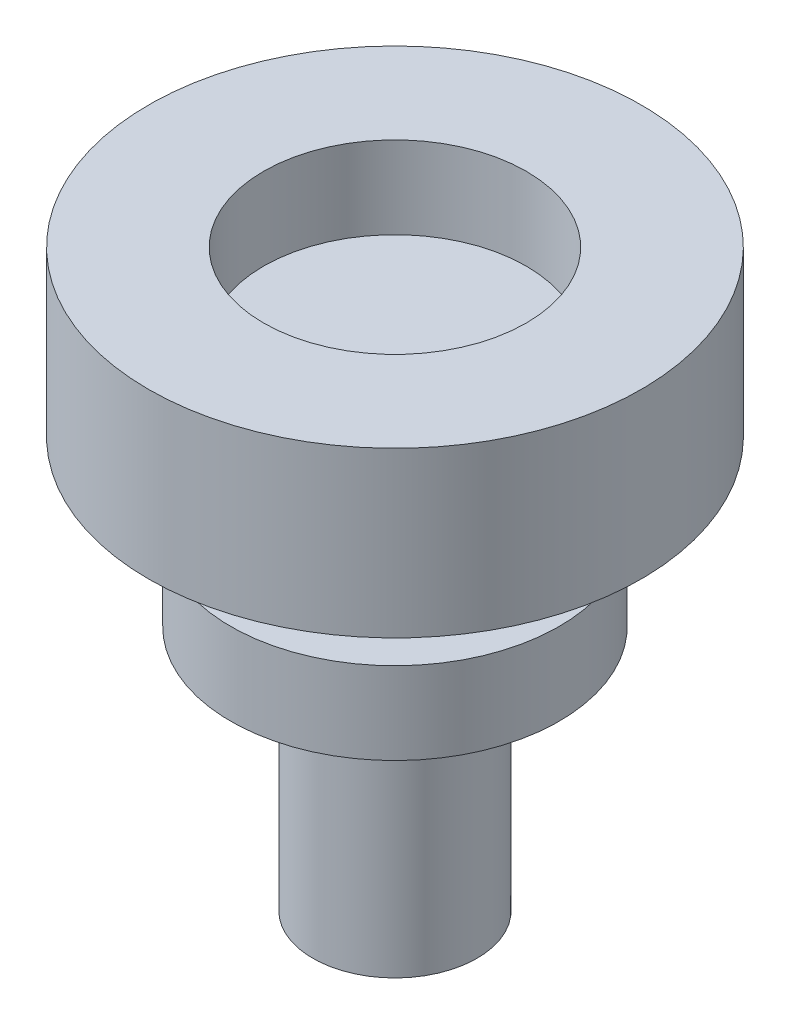
from build123d import *

# Parameters (mm, degrees)
SKETCH1_R           = 3
SKETCH1_R_2         = 1.6
BOSS_EXTRUDE1_DEPTH = 2
SKETCH1_3_R         = 1.6
BOSS_EXTRUDE2_DEPTH = 1
SKETCH5_R           = 1.5
BOSS_EXTRUDE3_DEPTH = 1
SKETCH6_R           = 2
BOSS_EXTRUDE4_DEPTH = 1
SKETCH8_R           = 1
BOSS_EXTRUDE5_DEPTH = 3


with BuildPart() as part:
    # Sketch1 → Boss-Extrude1 (new body)
    with BuildSketch(Plane(origin=(0, 0, 0), x_dir=(1, 0, 0), z_dir=(0, 1, 0))):
        with Locations((-0.522013312, 0.511138034)):
            Circle(SKETCH1_R)
        with Locations((-0.522013312, 0.511138034)):
            Circle(SKETCH1_R_2, mode=Mode.SUBTRACT)
    extrude(amount=BOSS_EXTRUDE1_DEPTH)

    # Sketch1_3 → Boss-Extrude2 (add)
    with BuildSketch(Plane(origin=(0, 0, 0), x_dir=(1, 0, 0), z_dir=(0, 1, 0))):
        with Locations((-0.522013312, 0.511138034)):
            Circle(SKETCH1_3_R)
    extrude(amount=BOSS_EXTRUDE2_DEPTH)

    # Sketch5 → Boss-Extrude3 (add)
    with BuildSketch(Plane.XZ):
        with Locations((-0.522013312, -0.511138034)):
            Circle(SKETCH5_R)
    extrude(amount=BOSS_EXTRUDE3_DEPTH)

    # Sketch6 → Boss-Extrude4 (add)
    with BuildSketch(Plane.XZ.offset(1)):
        with Locations((-0.522013312, -0.511138034)):
            Circle(SKETCH6_R)
    extrude(amount=BOSS_EXTRUDE4_DEPTH)

    # Sketch8 → Boss-Extrude5 (add)
    with BuildSketch(Plane(origin=(0, -2, 0), x_dir=(-1, 0, 0), z_dir=(0, -1, 0))):
        with Locations((0.522013312, 0.511138034)):
            Circle(SKETCH8_R)
    extrude(amount=BOSS_EXTRUDE5_DEPTH)


solid = part.part
